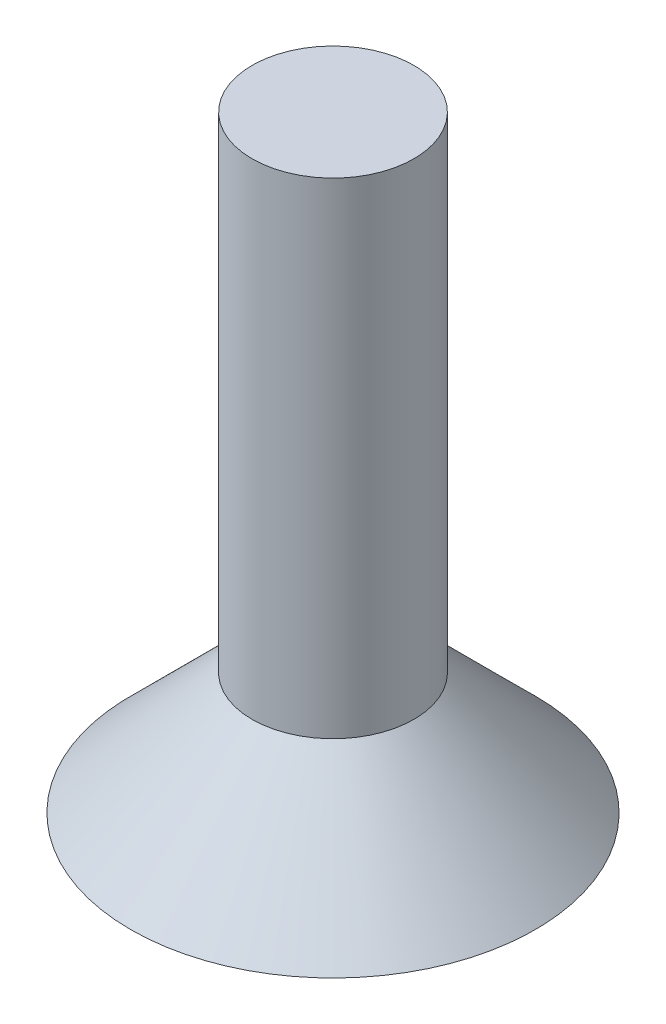
from build123d import *


with BuildPart() as part:
    # Эскиз1 → Повернуть1 (revolve)
    with BuildSketch(Plane.XY):
        Polygon((0, 15), (2, 15), (2, 3), (5, 0), (0, 0), align=None)
    revolve(axis=Axis((0, 49.838039672, 0), (0, -1, 0)))


solid = part.part
